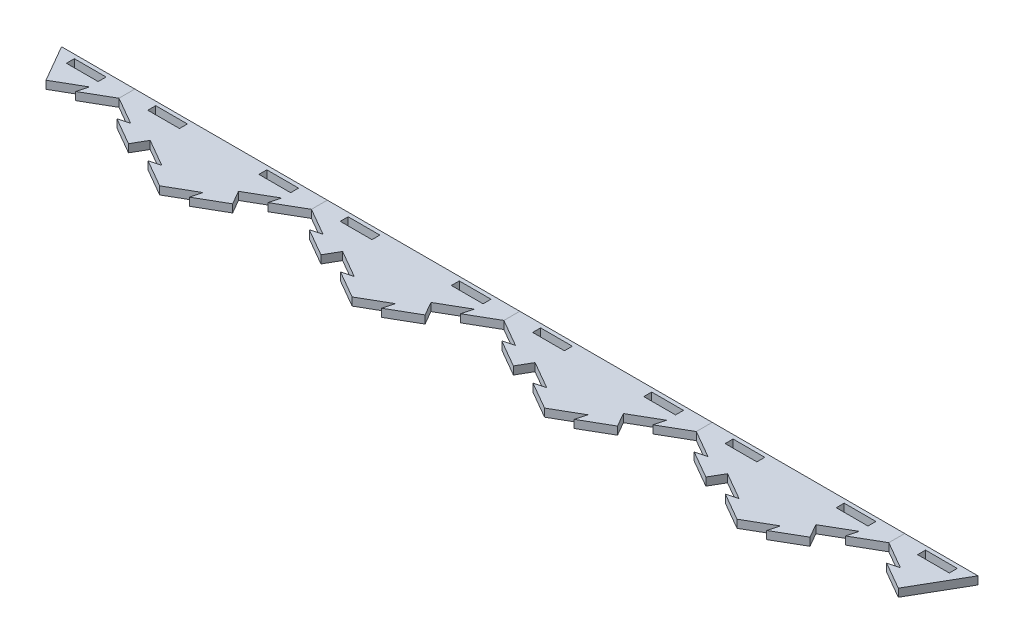
from build123d import *

# Parameters (mm, degrees)
BOSS_EXTRUDE1_DEPTH = 6.35
CUT_EXTRUDE4_DEPTH  = 155.110195964
BOSS_EXTRUDE4_DEPTH = 6.35
CIRPATTERN1_COUNT   = 2
CIRPATTERN1_ANGLE   = 60
SKETCH12_W          = 153.979316792
SKETCH12_H          = 120.65
CUT_EXTRUDE5_DEPTH  = 155.110195964
SKETCH13_W          = 25.4
SKETCH13_H          = 6.35
CUT_EXTRUDE6_DEPTH  = 90.126497182
LPATTERN1_COUNT     = 5
LPATTERN1_PITCH     = 153.979316882
LPATTERN1_2_COUNT   = 2
LPATTERN1_2_PITCH   = 153.979316882
SKETCH14_W          = 25.4
SKETCH14_H          = 6.35
CUT_EXTRUDE7_DEPTH  = 695.360232872


with BuildPart() as part:
    # Sketch1 → Boss-Extrude1 (new body)
    with BuildSketch(Plane(origin=(0, 0, 0), x_dir=(1, 0, 0), z_dir=(0, 1, 0))):
        Polygon((-76.989658396, 0), (0, -44.45), (76.989658396, 0), (76.989658396, 88.9), (0, 133.35), (-76.989658396, 88.9), align=None)
    extrude(amount=-BOSS_EXTRUDE1_DEPTH)

    # Sketch10 → Cut-Extrude4 (cut, through all)
    with BuildSketch(Plane(origin=(0, 0, 0), x_dir=(1, 0, 0), z_dir=(0, 1, 0))):
        Polygon((-21.997045256, -31.75), (-13.322783942, -29.425738686), (-35.319829198, -16.725738686), (-38.494829198, -22.225), align=None)
    cut_extrude4 = extrude(amount=-CUT_EXTRUDE4_DEPTH, mode=Mode.SUBTRACT)

    # Sketch11 → Boss-Extrude4 (add)
    with BuildSketch(Plane(origin=(0, 0, 0), x_dir=(1, 0, 0), z_dir=(0, 1, 0))):
        Polygon((-38.494829198, -22.225), (-41.669829198, -27.724261314), (-63.666874454, -15.024261314), (-54.99261314, -12.7), align=None)
    boss_extrude4 = extrude(amount=-BOSS_EXTRUDE4_DEPTH)

    # CirPattern1: Cut-Extrude4, Boss-Extrude4 ×2 about axis
    cirpattern1_axis = Axis((0, 0, -44.45), (0, 1, 0))
    add([cut_extrude4.rotate(cirpattern1_axis, i * CIRPATTERN1_ANGLE / (CIRPATTERN1_COUNT - 1)) for i in range(1, CIRPATTERN1_COUNT)], mode=Mode.SUBTRACT)
    add([boss_extrude4.rotate(cirpattern1_axis, i * CIRPATTERN1_ANGLE / (CIRPATTERN1_COUNT - 1)) for i in range(1, CIRPATTERN1_COUNT)])

    # Sketch12 → Cut-Extrude5 (cut, through all)
    with BuildSketch(Plane(origin=(0, 0, 0), x_dir=(1, 0, 0), z_dir=(0, 1, 0))):
        with Locations((0, 73.025)):
            Rectangle(SKETCH12_W, SKETCH12_H)
    extrude(amount=-CUT_EXTRUDE5_DEPTH, mode=Mode.SUBTRACT)

    # Sketch13 → Cut-Extrude6 (cut, through all)
    with BuildSketch(Plane(origin=(0, 0, 0), x_dir=(1, 0, 0), z_dir=(0, 1, 0))):
        with Locations((-44.45, 6.35)):
            Rectangle(SKETCH13_W, SKETCH13_H)
        with Locations((44.45, 6.35)):
            Rectangle(SKETCH13_W, SKETCH13_H)
    extrude(amount=-CUT_EXTRUDE6_DEPTH, mode=Mode.SUBTRACT)


with BuildPart() as lpattern1_1:
    # LPattern1: pattern copy
    add(part.part.moved(Location(Vector(1, 0, 0) * (1 * LPATTERN1_PITCH))))


with BuildPart() as lpattern1_2:
    # LPattern1: pattern copy
    add(part.part.moved(Location(Vector(1, 0, 0) * (2 * LPATTERN1_PITCH))))


with BuildPart() as lpattern1_3:
    # LPattern1: pattern copy
    add(part.part.moved(Location(Vector(1, 0, 0) * (3 * LPATTERN1_PITCH))))


with BuildPart() as lpattern1_4:
    # LPattern1: pattern copy
    add(part.part.moved(Location(Vector(1, 0, 0) * (4 * LPATTERN1_PITCH))))


with BuildPart() as lpattern1_2_1:
    # LPattern1 2: pattern copy
    add(part.part.moved(Location(Vector(-1, 0, 0) * (1 * LPATTERN1_2_PITCH))))


with BuildPart() as cut_extrude7_tool:
    # Sketch14 → Cut-Extrude7 (new, through all)
    # profile 1 of 2: a face of its own
    with BuildSketch(Plane(origin=(0, 0, 0), x_dir=(1, 0, 0), z_dir=(0, 1, 0))):
        Polygon((593.920222272, -31.75), (615.917267528, -44.45), (637.914312784, -31.75), (635.59005147, -40.424261314), (657.587096726, -27.724261314), (651.237096726, -16.725738686), (673.234141982, -4.025738686), (670.909880668, -12.7), (692.906925924, 0), (692.906925924, 12.7), (597.586396481, 12.7), (580.59743833, -16.725738686), (602.594483586, -29.425738686), align=None)
        with Locations((660.367267528, 6.35)):
            Rectangle(SKETCH14_W, SKETCH14_H, mode=Mode.SUBTRACT)
    # profile 2 of 2: a face of its own
    with BuildSketch(Plane(origin=(0, 0, 0), x_dir=(1, 0, 0), z_dir=(0, 1, 0))):
        Polygon((-230.968975278, -44.45), (-153.979316882, -44.45), (-134.30653294, -40.424261314), (-112.309487684, -27.724261314), (-135.648445835, 12.7), (-230.968975278, 12.7), align=None)
    extrude(amount=-CUT_EXTRUDE7_DEPTH)


with BuildPart() as lpattern1_4_1:
    add(lpattern1_4.part)

    # Cut-Extrude7: cut by cut_extrude7_tool
    add(cut_extrude7_tool.part, mode=Mode.SUBTRACT)


with BuildPart() as lpattern1_2_1_1:
    add(lpattern1_2_1.part)

    # Cut-Extrude7: cut by cut_extrude7_tool
    add(cut_extrude7_tool.part, mode=Mode.SUBTRACT)


solid = Compound([part.part, lpattern1_1.part, lpattern1_2.part, lpattern1_3.part, lpattern1_4_1.part, lpattern1_2_1_1.part])
